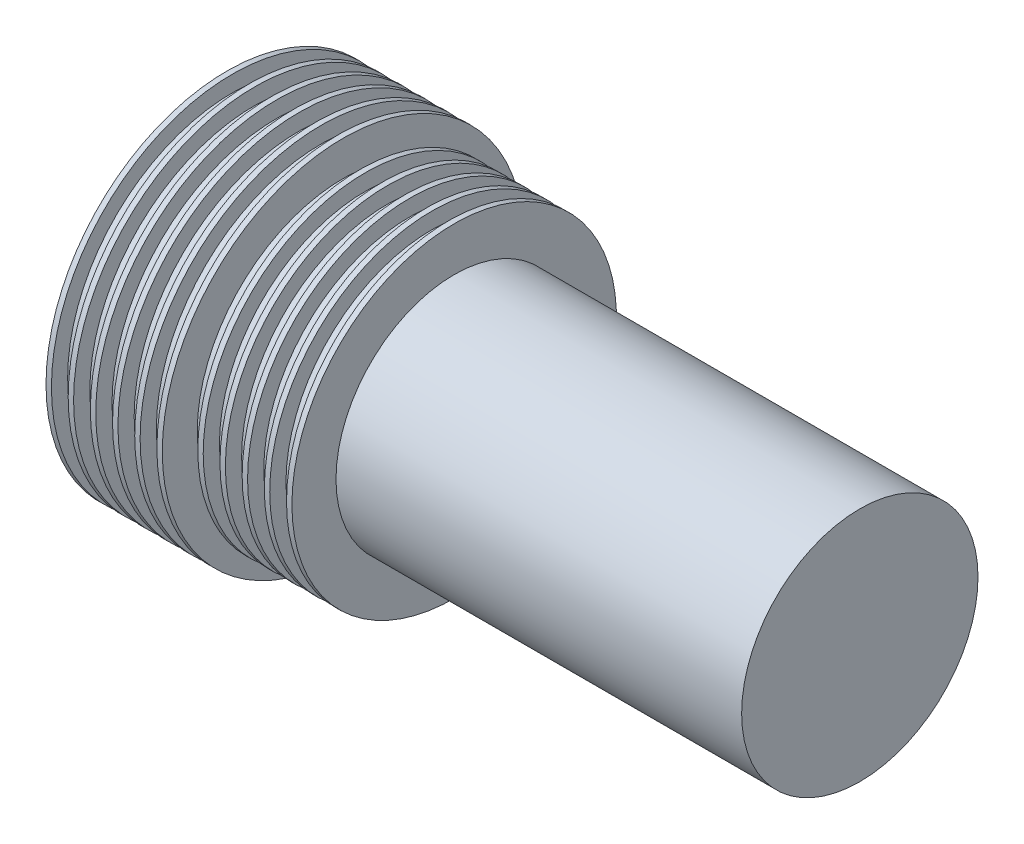
from build123d import *


with BuildPart() as part:
    # Sketch1 → Revolve1 (revolve)
    with BuildSketch(Plane.XY):
        Polygon((0, 0), (29.718, 0), (29.718, 5.5499), (17.018, 5.5499), (10.668, 5.5499), (10.668, 7.62), (10.414, 7.62), (10.414, 6.858), (9.6266, 6.858), (9.6266, 7.62), (9.3726, 7.62), (9.3726, 6.858), (8.5852, 6.858), (8.5852, 7.62), (8.3312, 7.62), (8.3312, 6.858), (7.5438, 6.858), (7.5438, 7.62), (7.2898, 7.62), (7.2898, 6.858), (6.5024, 6.858), (6.5024, 7.62), (6.2484, 7.62), (6.2484, 6.858), (5.461, 6.858), (5.461, 7.62), (5.461, 8.500000018), (5.207, 8.500000018), (5.207, 7.738000018), (4.4196, 7.738000018), (4.4196, 8.500000018), (4.1656, 8.500000018), (4.1656, 7.738000018), (3.3782, 7.738000018), (3.3782, 8.500000018), (3.1242, 8.500000018), (3.1242, 7.738000018), (2.3368, 7.738000018), (2.3368, 8.500000018), (2.0828, 8.500000018), (2.0828, 7.738000018), (1.2954, 7.738000018), (1.2954, 8.500000018), (1.0414, 8.500000018), (1.0414, 7.738000018), (0.254, 7.738000018), (0.254, 8.500000018), (0, 8.500000018), align=None)
    revolve(axis=Axis((0, 0, 0), (1, 0, 0)))


solid = part.part
